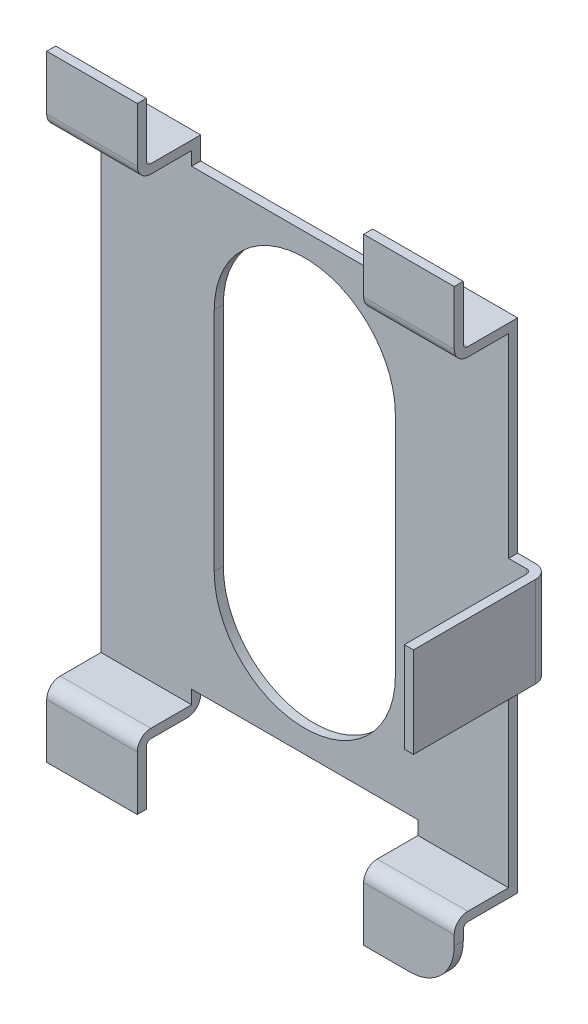
from build123d import *

# Parameters (mm, degrees)
EXTRUDE_THIN2_DEPTH      = 2.25
EXTRUDE_THIN2_DEPTH_BACK = 2.25
SKETCH2_W                = 2.5
SKETCH2_H                = 0.8
EXTRUDE1_DEPTH           = 4
EXTRUDE1_DEPTH_BACK      = 4
S2D0010_W                = 0.5
S2D0010_H                = 2.5
EXTRUDE2_DEPTH           = 0.17
EXTRUDE_THIN3_DEPTH      = 0.5
EXTRUDE_THIN3_DEPTH_BACK = 0.5
FILLET1_R                = 0.15
FILLET2_R                = 0.49


with BuildPart() as part:
    # Sketch1 → Extrude-Thin2 (new body, two sides)
    with BuildSketch(Plane(origin=(0, 0, 0), x_dir=(0, -1, 0), z_dir=(1, 0, 0))) as extrude_thin2_sk:
        with BuildLine():
            Line((-3.4, -0.6), (-2.8, -0.6))
            ThreePointArc((-2.8, -0.6), (-2.693933983, -0.556066017), (-2.65, -0.45))
            Line((-2.65, -0.45), (-2.65, 0))
            Line((-2.65, 0), (2.65, 0))
            Line((2.65, 0), (2.65, -0.45))
            ThreePointArc((2.65, -0.45), (2.693933983, -0.556066017), (2.8, -0.6))
            Line((2.8, -0.6), (3.4, -0.6))
            Line((3.4, -0.6), (3.4, -0.5))
            Line((3.4, -0.5), (2.8, -0.5))
            ThreePointArc((2.8, -0.5), (2.764644661, -0.485355339), (2.75, -0.45))
            Line((2.75, -0.45), (2.75, 0.1))
            Line((2.75, 0.1), (-2.75, 0.1))
            Line((-2.75, 0.1), (-2.75, -0.45))
            ThreePointArc((-2.75, -0.45), (-2.764644661, -0.485355339), (-2.8, -0.5))
            Line((-2.8, -0.5), (-3.4, -0.5))
            Line((-3.4, -0.5), (-3.4, -0.6))
        make_face()
    extrude(amount=EXTRUDE_THIN2_DEPTH)
    extrude(extrude_thin2_sk.sketch, amount=-EXTRUDE_THIN2_DEPTH_BACK)

    # Sketch2 → Extrude1 (cut, two sides)
    with BuildSketch(Plane(origin=(0, 0, 0), x_dir=(-1, 0, 0), z_dir=(0, 1, 0))) as extrude1_sk:
        with Locations((0, 0.4)):
            Rectangle(SKETCH2_W, SKETCH2_H)
    extrude(amount=EXTRUDE1_DEPTH, mode=Mode.SUBTRACT)
    extrude(extrude1_sk.sketch, amount=-EXTRUDE1_DEPTH_BACK, mode=Mode.SUBTRACT)

    # S2D0010 → Extrude2 (cut)
    with BuildSketch(Plane(origin=(0, 0, 0), x_dir=(0, -1, 0), z_dir=(0, 0, 1))):
        with BuildLine():
            Line((1.25, 1), (-1.25, 1))
            ThreePointArc((-1.25, 1), (-2.25, 0), (-1.25, -1))
            Line((-1.25, -1), (1.25, -1))
            ThreePointArc((1.25, -1), (2.25, 0), (1.25, 1))
        make_face()
        with Locations((2.75, 0)):
            Rectangle(S2D0010_W, S2D0010_H)
        with Locations((-2.75, 0)):
            Rectangle(S2D0010_W, S2D0010_H)
    extrude(amount=-EXTRUDE2_DEPTH, mode=Mode.SUBTRACT)

    # S2D0012 → Extrude-Thin3 (add, two sides)
    with BuildSketch(Plane(origin=(0, 0, 0), x_dir=(1, 0, 0), z_dir=(0, 1, 0))) as extrude_thin3_sk:
        with BuildLine():
            Line((2.25, 0), (2.45, 0))
            ThreePointArc((2.45, 0), (2.485355339, -0.014644661), (2.5, -0.05))
            Line((2.5, -0.05), (2.5, -1.4))
            Line((2.5, -1.4), (2.6, -1.4))
            Line((2.6, -1.4), (2.6, -0.05))
            ThreePointArc((2.6, -0.05), (2.556066017, 0.056066017), (2.45, 0.1))
            Line((2.45, 0.1), (2.25, 0.1))
            Line((2.25, 0.1), (2.25, 0))
        make_face()
    extrude(amount=EXTRUDE_THIN3_DEPTH)
    extrude(extrude_thin3_sk.sketch, amount=-EXTRUDE_THIN3_DEPTH_BACK)

    # Fillet1
    fillet1_edges = [part.edges().sort_by_distance(p)[0] for p in [
        (-1.75, -2.75, -0.1),
    ]]
    fillet(fillet1_edges, radius=FILLET1_R)

    # Fillet2
    fillet2_edges = [part.edges().sort_by_distance(p)[0] for p in [
        (2.25, -3.4, 0.55),
    ]]
    fillet(fillet2_edges, radius=FILLET2_R)


solid = part.part
